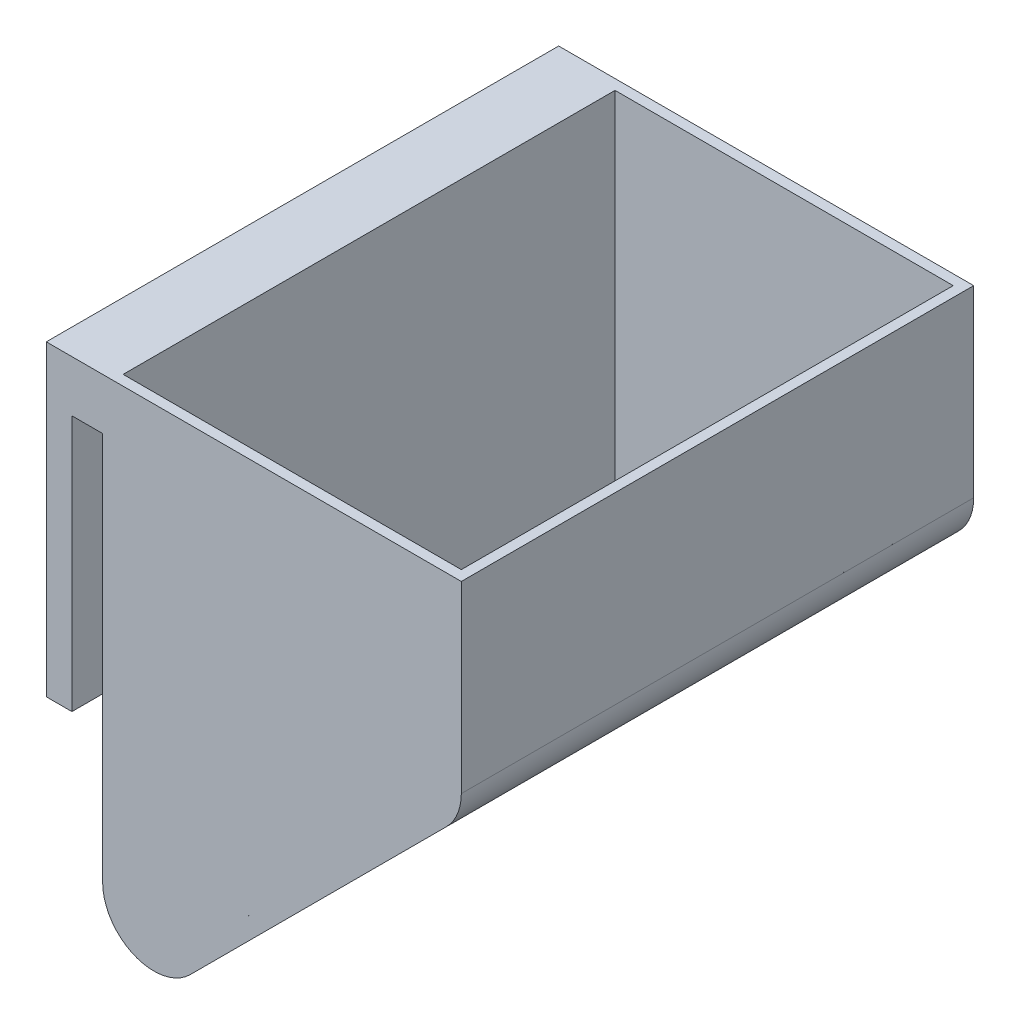
from build123d import *

# Parameters (mm, degrees)
BOSS_EXTRUDE2_DEPTH = 100
SKETCH2_W           = 66
SKETCH2_H           = 96
CUT_EXTRUDE5_DEPTH  = 10
CUT_EXTRUDE6_DEPTH  = 96
FILLET6_R           = 10


with BuildPart() as part:
    # Sketch1 → Boss-Extrude2 (new body)
    with BuildSketch(Plane.XY):
        Polygon((-11, 0), (-11, -60), (-6, -60), (-6, -10), (0, -10), (0, -110), (70, -40), (70, 0), align=None)
    extrude(amount=BOSS_EXTRUDE2_DEPTH)

    # Sketch2 → Cut-Extrude5 (cut)
    with BuildSketch(Plane(origin=(0, 0, 0), x_dir=(1, 0, 0), z_dir=(0, 1, 0))):
        with Locations((35, -50)):
            Rectangle(SKETCH2_W, SKETCH2_H)
    extrude(amount=-CUT_EXTRUDE5_DEPTH, mode=Mode.SUBTRACT)

    # Sketch5 → Cut-Extrude6 (cut)
    with BuildSketch(Plane(origin=(2, 0, 98), x_dir=(1, 0, 0), z_dir=(0, 0, 1))):
        Polygon((0, 0), (0, -103.757359313), (66, -37.763932022), (66, 0), align=None)
    extrude(amount=-CUT_EXTRUDE6_DEPTH, mode=Mode.SUBTRACT)

    # Fillet6
    fillet6_edges = [part.edges().sort_by_distance(p)[0] for p in [
        (70, -40, 50),
        (0, -110, 50),
        (68, -37.763932022, 50),
        (2, -103.757359313, 50),
    ]]
    fillet(fillet6_edges, radius=FILLET6_R)


solid = part.part
